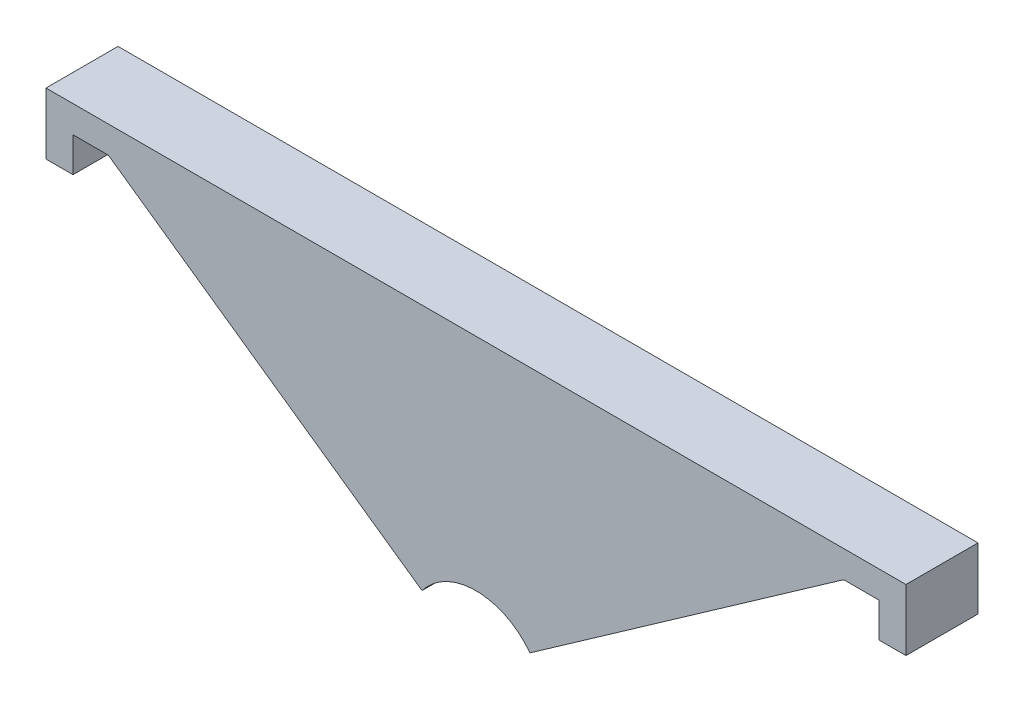
from build123d import *

# Parameters (mm, degrees)
BOSS_EXTRU_1_DEPTH = 8


with BuildPart() as part:
    # Esquisse2 → Boss.-Extru.1 (new body)
    with BuildSketch(Plane.XY):
        with BuildLine():
            Line((-47.75, 65.629607354), (-44.75, 65.629607354))
            Line((-44.75, 65.629607354), (-44.75, 69.468928374))
            Line((-44.75, 69.468928374), (-40.831689929, 69.468928374))
            Line((-40.831689929, 69.468928374), (-5.991442082, 45.011388011))
            ThreePointArc((-5.991442082, 45.011388011), (0, 48), (5.991442082, 45.011388011))
            Line((5.991442082, 45.011388011), (40.831689929, 69.468928374))
            Line((40.831689929, 69.468928374), (44.75, 69.468928374))
            Line((44.75, 69.468928374), (44.75, 65.629607354))
            Line((44.75, 65.629607354), (47.75, 65.629607354))
            Line((47.75, 65.629607354), (47.75, 72.468928374))
            Line((47.75, 72.468928374), (-47.75, 72.468928374))
            Line((-47.75, 72.468928374), (-47.75, 65.629607354))
        make_face()
    extrude(amount=BOSS_EXTRU_1_DEPTH)


solid = part.part
